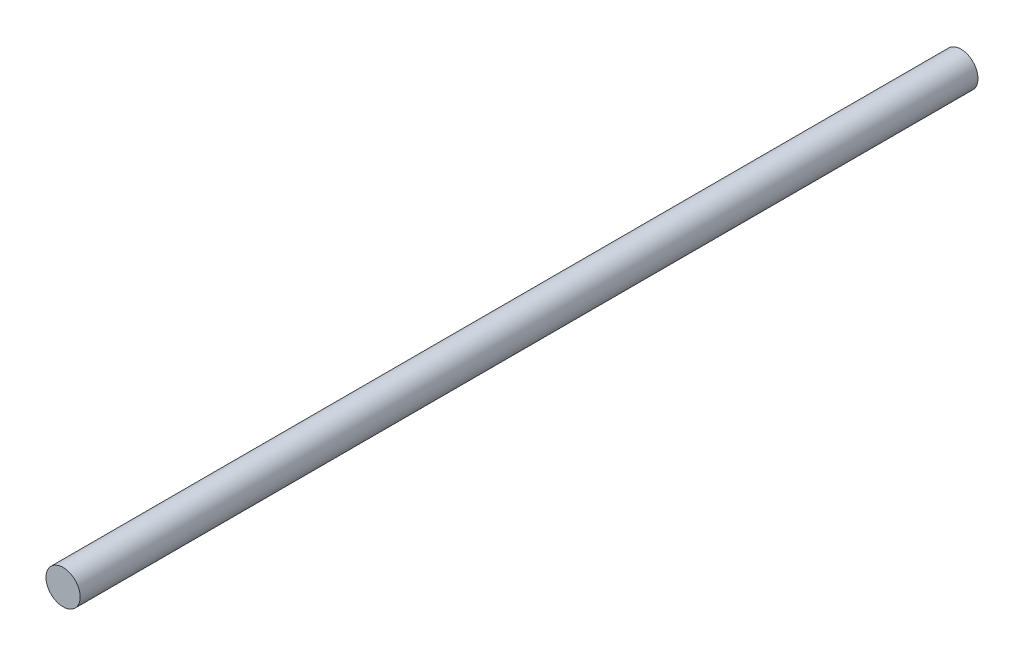
from build123d import *

# Parameters (mm, degrees)
SKETCH1_R           = 4
BOSS_EXTRUDE1_DEPTH = 210


with BuildPart() as part:
    # Sketch1 → Boss-Extrude1 (new body)
    with BuildSketch(Plane.XY):
        Circle(SKETCH1_R)
    extrude(amount=BOSS_EXTRUDE1_DEPTH)


solid = part.part
